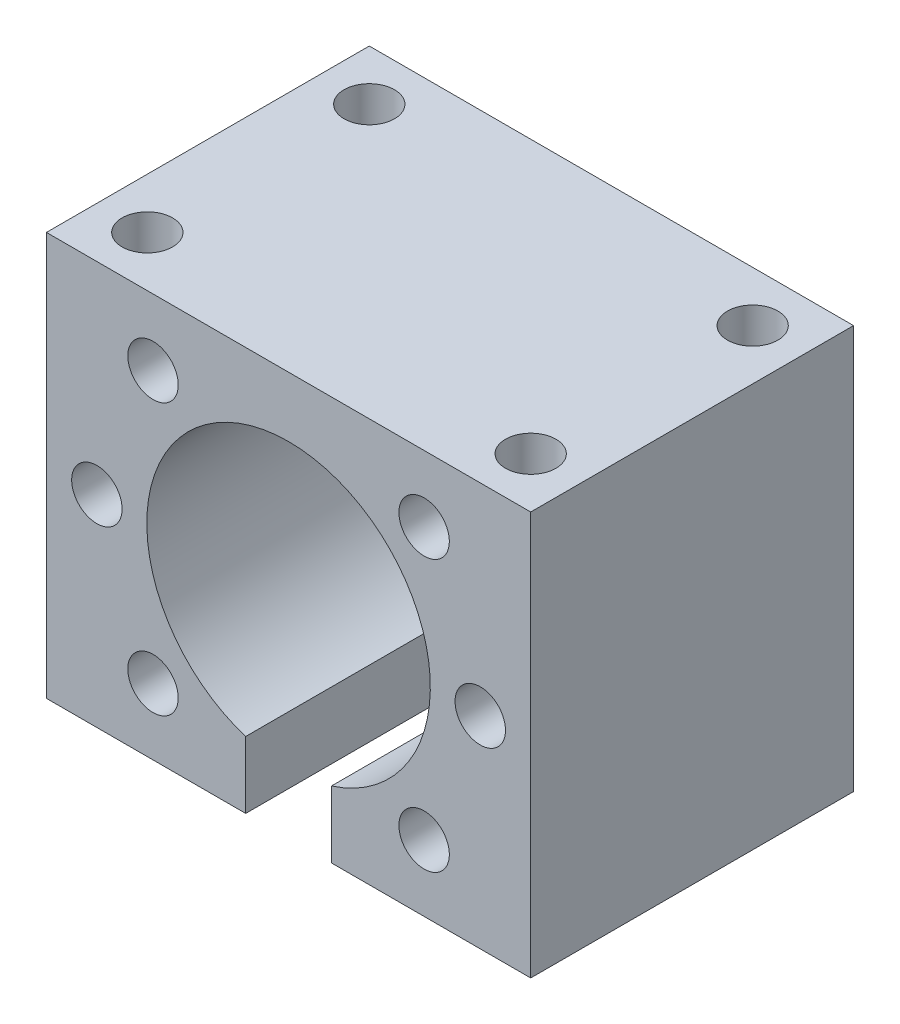
from build123d import *

# Parameters (mm, degrees)
BOSS_EXTRUDE1_DEPTH         = 32
TAP_DRILL_FOR_M5_TAP1_D     = 5
TAP_DRILL_FOR_M5_TAP1_DEPTH = 20
TAP_DRILL_FOR_M5_TAP1_TIP   = 1.502151548
TAP_DRILL_FOR_M5_TAP2_D     = 5
TAP_DRILL_FOR_M5_TAP2_DEPTH = 20
TAP_DRILL_FOR_M5_TAP2_TIP   = 1.502151548


with BuildPart() as part:
    # Sketch1 → Boss-Extrude1 (new body)
    with BuildSketch(Plane.XY):
        with BuildLine():
            Line((-24, 40), (-24, 0))
            Line((-24, 0), (-4.25, 0))
            Line((-4.25, 0), (-4.25, 6.608211471))
            ThreePointArc((-4.25, 6.608211471), (0, 34.05), (4.25, 6.608211471))
            Line((4.25, 6.608211471), (4.25, 0))
            Line((4.25, 0), (24, 0))
            Line((24, 0), (24, 40))
            Line((24, 40), (-24, 40))
        make_face()
    extrude(amount=BOSS_EXTRUDE1_DEPTH)

    # Tap Drill for M5 Tap1
    with Locations(Plane(origin=(-13.435028843, 33.435028843, 32), x_dir=(1, 0, 0), z_dir=(0, 0, 1))):
        with Locations((0, 0), (-5.564971157, -13.435028843), (0, -26.870057686), (26.870057686, -26.870057686), (32.435028843, -13.435028843), (26.870057686, 0)):
            Hole(TAP_DRILL_FOR_M5_TAP1_D / 2, depth=TAP_DRILL_FOR_M5_TAP1_DEPTH)
            with Locations((0, 0, -(TAP_DRILL_FOR_M5_TAP1_DEPTH + TAP_DRILL_FOR_M5_TAP1_TIP / 2))):  # 118° drill point
                Cone(0, TAP_DRILL_FOR_M5_TAP1_D / 2, TAP_DRILL_FOR_M5_TAP1_TIP, mode=Mode.SUBTRACT)

    # Tap Drill for M5 Tap2
    with Locations(Plane(origin=(-19, 40, 5), x_dir=(0, 0, 1), z_dir=(0, 1, 0))):
        with Locations((0, 0), (22, 0), (22, 38), (0, 38)):
            Hole(TAP_DRILL_FOR_M5_TAP2_D / 2, depth=TAP_DRILL_FOR_M5_TAP2_DEPTH)
            with Locations((0, 0, -(TAP_DRILL_FOR_M5_TAP2_DEPTH + TAP_DRILL_FOR_M5_TAP2_TIP / 2))):  # 118° drill point
                Cone(0, TAP_DRILL_FOR_M5_TAP2_D / 2, TAP_DRILL_FOR_M5_TAP2_TIP, mode=Mode.SUBTRACT)


solid = part.part
